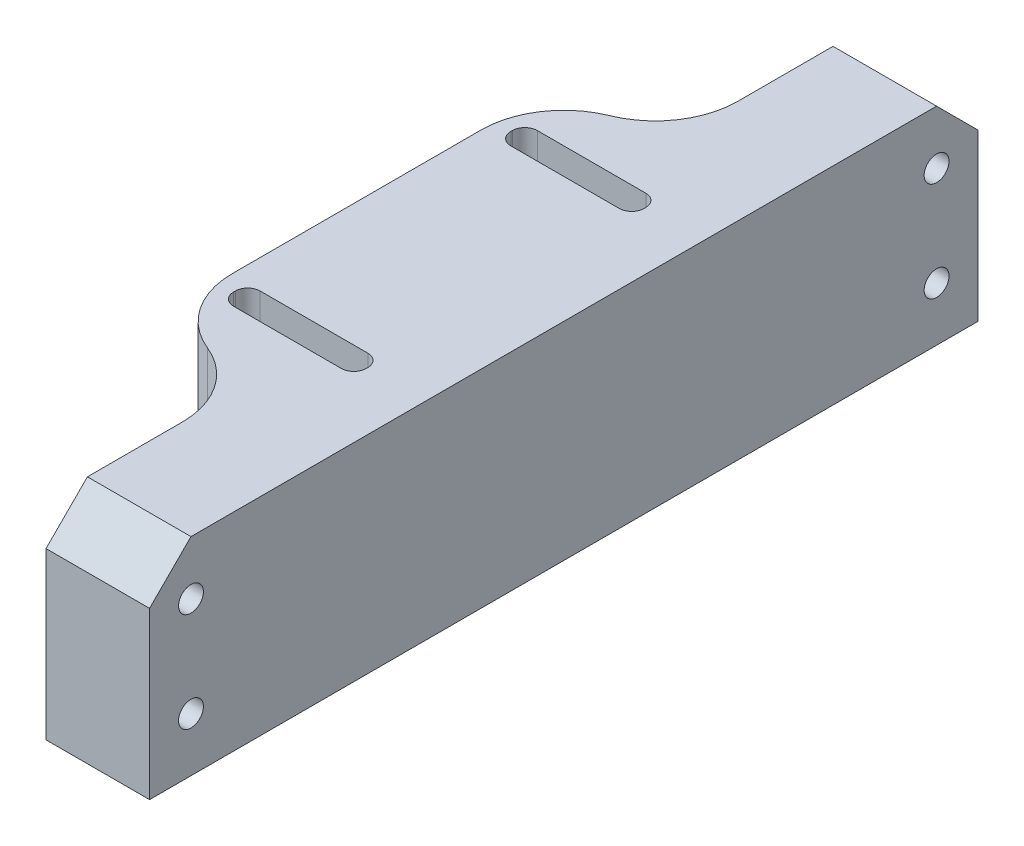
from build123d import *

# Parameters (mm, degrees)
SKETCH_1_W          = 16
SKETCH_1_H          = 3.2
SKETCH_1_W_2        = 16.095473014
EXTRUDE_1_DEPTH     = 25
SKETCH_2_R          = 1.5
CUT_EXTRUDE_1_DEPTH = 13.5
SKETCH_3_R          = 1.5
CUT_EXTRUDE_2_DEPTH = 13.5
FILLET_6_R          = 10
FILLET_7_R          = 1.5
CHAMFER_1_SIZE      = 5
FILLET_8_R          = 10
SKETCH1_W           = 21
SKETCH1_H           = 8
CUT_EXTRUDE1_DEPTH  = 7


with BuildPart() as part:
    # Эскиз1 → Бобышка-Вытянуть1 (new body)
    with BuildSketch(Plane(origin=(0, 0, 0), x_dir=(1, 0, 0), z_dir=(0, 1, 0))):
        Polygon((-12.5, -25), (0, -25), (0, -50), (12.5, -50), (12.5, 50), (0, 50), (0, 25), (-12.5, 25), align=None)
        with Locations((-2.5, -16.75)):
            Rectangle(SKETCH_1_W, SKETCH_1_H, mode=Mode.SUBTRACT)
        with Locations((-2.5, 16.75)):
            Rectangle(SKETCH_1_W_2, SKETCH_1_H, mode=Mode.SUBTRACT)
    extrude(amount=EXTRUDE_1_DEPTH)

    # Эскиз2 → Вырез-Вытянуть1 (cut, through all)
    with BuildSketch(Plane.ZY):
        with Locations((-45, 6.5)):
            Circle(SKETCH_2_R)
        with Locations((-45, 18.5)):
            Circle(SKETCH_2_R)
    extrude(amount=-CUT_EXTRUDE_1_DEPTH, mode=Mode.SUBTRACT)

    # Эскиз3 → Вырез-Вытянуть2 (cut, through all)
    with BuildSketch(Plane.ZY):
        with Locations((45, 6.5)):
            Circle(SKETCH_3_R)
        with Locations((45, 18.5)):
            Circle(SKETCH_3_R)
    extrude(amount=-CUT_EXTRUDE_2_DEPTH, mode=Mode.SUBTRACT)

    # Скругление6
    fillet_6_edges = [part.edges().sort_by_distance(p)[0] for p in [
        (-12.5, 12.5, 25),
        (-12.5, 12.5, -25),
    ]]
    fillet(fillet_6_edges, radius=FILLET_6_R)

    # Скругление7
    fillet_7_edges = [part.edges().sort_by_distance(p)[0] for p in [
        (-10.5, 12.5, 15.15),
        (-10.5, 12.5, 18.35),
        (5.5, 12.5, 18.35),
        (5.5, 12.5, 15.15),
        (-10.547736507, 12.5, -18.35),
        (-10.547736507, 12.5, -15.15),
        (5.547736507, 12.5, -15.15),
        (5.547736507, 12.5, -18.35),
    ]]
    fillet(fillet_7_edges, radius=FILLET_7_R)

    # Фаска1
    chamfer_1_edges = [part.edges().sort_by_distance(p)[0] for p in [
        (6.25, 25, 50),
        (6.25, 25, -50),
    ]]
    chamfer(chamfer_1_edges, length=CHAMFER_1_SIZE)

    # Скругление8
    fillet_8_edges = [part.edges().sort_by_distance(p)[0] for p in [
        (0, 12.5, 25),
        (0, 12.5, -25),
    ]]
    fillet(fillet_8_edges, radius=FILLET_8_R)

    # Sketch1 → Cut-Extrude1 (cut)
    with BuildSketch(Plane.XZ):
        with Locations((-2, 16.75)):
            Rectangle(SKETCH1_W, SKETCH1_H)
        with Locations((-2, -16.75)):
            Rectangle(SKETCH1_W, SKETCH1_H)
    extrude(amount=-CUT_EXTRUDE1_DEPTH, mode=Mode.SUBTRACT)


solid = part.part
